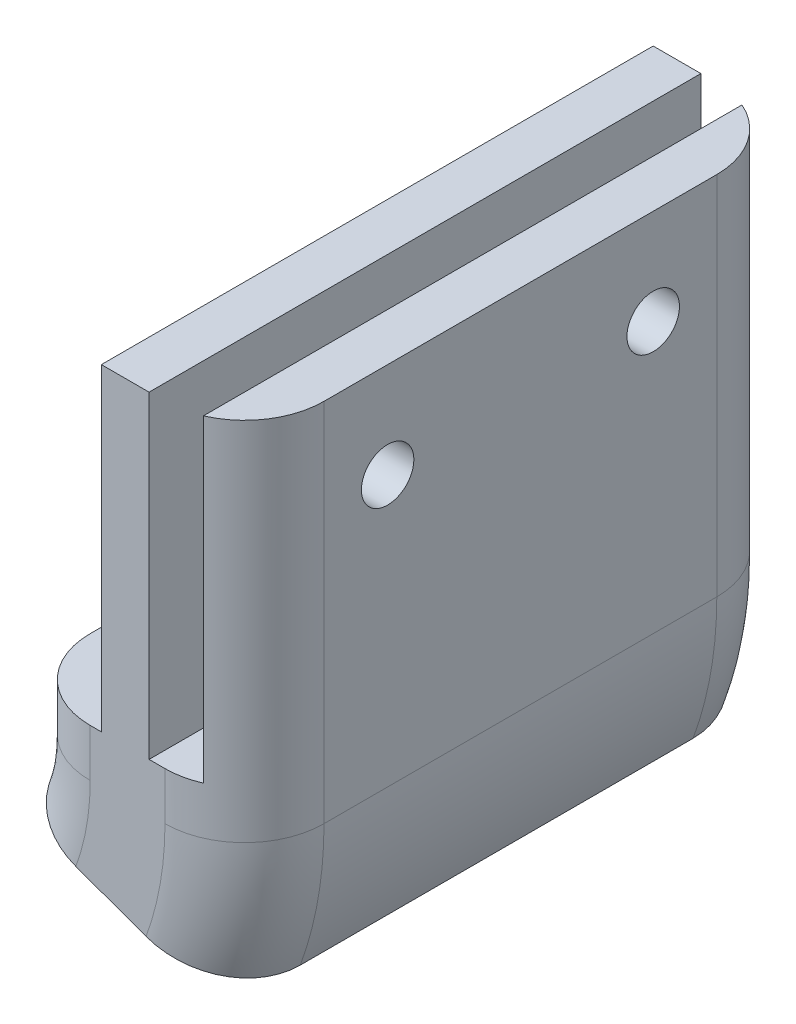
from build123d import *

# Parameters (mm, degrees)
BOSS_EXTRU_1_DEPTH      = 3
R_VOLUTION1_ANGLE       = 20
ESQUISSE5_W             = 3
ESQUISSE5_H             = 34.7
BOSS_EXTRU_2_DEPTH      = 20
ESQUISSE6_R             = 1.65
ENL_V_MAT_EXTRU_1_DEPTH = 16.303073792
ENL_V_MAT_EXTRU_3_REACH = 11


with BuildPart() as part:
    # Esquisse1 → Boss.-Extru.1 (new body)
    with BuildSketch(Plane(origin=(0, 0, 0), x_dir=(1, 0, 0), z_dir=(0, 1, 0))):
        with BuildLine():
            Line((2.35, -17.35), (-2.35, -17.35))
            ThreePointArc((-2.35, -17.35), (-5.885533906, -15.885533906), (-7.35, -12.35))
            Line((-7.35, -12.35), (-7.35, 12.35))
            ThreePointArc((-7.35, 12.35), (-5.885533906, 15.885533906), (-2.35, 17.35))
            Line((-2.35, 17.35), (2.35, 17.35))
            ThreePointArc((2.35, 17.35), (5.885533906, 15.885533906), (7.35, 12.35))
            Line((7.35, 12.35), (7.35, -12.35))
            ThreePointArc((7.35, -12.35), (5.885533906, -15.885533906), (2.35, -17.35))
        make_face()
    extrude(amount=BOSS_EXTRU_1_DEPTH)

    # Esquisse4 → Révolution1 (revolve)
    with BuildSketch(Plane.XZ):
        with BuildLine():
            Line((2.35, -17.35), (-2.35, -17.35))
            ThreePointArc((-2.35, -17.35), (-5.885533906, -15.885533906), (-7.35, -12.35))
            Line((-7.35, -12.35), (-7.35, 12.35))
            ThreePointArc((-7.35, 12.35), (-5.885533906, 15.885533906), (-2.35, 17.35))
            Line((-2.35, 17.35), (2.35, 17.35))
            ThreePointArc((2.35, 17.35), (5.885533906, 15.885533906), (7.35, 12.35))
            Line((7.35, 12.35), (7.35, -12.35))
            ThreePointArc((7.35, -12.35), (5.885533906, -15.885533906), (2.35, -17.35))
        make_face()
    revolve(axis=Axis((-17.35, 0, 12.35), (0, 0, -1)), revolution_arc=R_VOLUTION1_ANGLE)

    # Esquisse5 → Boss.-Extru.2 (add)
    with BuildSketch(Plane(origin=(0, 3, 0), x_dir=(1, 0, 0), z_dir=(0, 1, 0))):
        with Locations((-0.15, 0)):
            Rectangle(ESQUISSE5_W, ESQUISSE5_H)
        with BuildLine():
            Line((7.35, -12.35), (7.35, 12.35))
            ThreePointArc((7.35, 12.35), (6.533300133, 15.088612788), (4.35, 16.932575695))
            Line((4.35, 16.932575695), (4.35, -16.932575695))
            ThreePointArc((4.35, -16.932575695), (6.533300133, -15.088612788), (7.35, -12.35))
        make_face()
    extrude(amount=BOSS_EXTRU_2_DEPTH)

    # Esquisse6 → Enlèv. mat.-Extru.1 (cut, through all)
    with BuildSketch(Plane(origin=(7.35, 0, 0), x_dir=(0, 0, -1), z_dir=(1, 0, 0))):
        with Locations((-8.35, 17)):
            Circle(ESQUISSE6_R)
        with Locations((8.35, 17)):
            Circle(ESQUISSE6_R)
    extrude(amount=-ENL_V_MAT_EXTRU_1_DEPTH, mode=Mode.SUBTRACT)

    # Esquisse8 → Enlèv. mat.-Extru.3 (cut, up to next)
    with BuildSketch(Plane.ZY.offset(1.65), mode=Mode.PRIVATE) as enl_v_mat_extru_3_sk1:
        Polygon((-6.704551733, 19.85), (-9.995448267, 19.85), (-11.640896534, 17), (-9.995448267, 14.15), (-6.704551733, 14.15), (-5.059103466, 17), align=None)
    enl_v_mat_extru_3_tool1 = extrude(enl_v_mat_extru_3_sk1.sketch, amount=-ENL_V_MAT_EXTRU_3_REACH, mode=Mode.PRIVATE) & part.part
    add(enl_v_mat_extru_3_tool1.solids().sort_by_distance((-1.65, 17, -8.35))[0], mode=Mode.SUBTRACT)
    # Esquisse8 → Enlèv. mat.-Extru.3 (cut, up to next)
    with BuildSketch(Plane.ZY.offset(1.65), mode=Mode.PRIVATE) as enl_v_mat_extru_3_sk2:
        Polygon((9.995448267, 19.85), (6.704551733, 19.85), (5.059103466, 17), (6.704551733, 14.15), (9.995448267, 14.15), (11.640896534, 17), align=None)
    enl_v_mat_extru_3_tool2 = extrude(enl_v_mat_extru_3_sk2.sketch, amount=-ENL_V_MAT_EXTRU_3_REACH, mode=Mode.PRIVATE) & part.part
    add(enl_v_mat_extru_3_tool2.solids().sort_by_distance((-1.65, 17, 8.35))[0], mode=Mode.SUBTRACT)


solid = part.part
